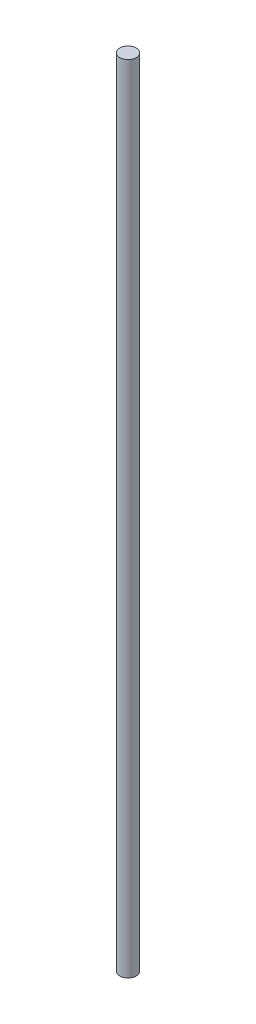
from build123d import *

# Parameters (mm, degrees)
SKETCH1_R           = 4.75
BOSS_EXTRUDE1_DEPTH = 455


with BuildPart() as part:
    # Sketch1 → Boss-Extrude1 (new body)
    with BuildSketch(Plane(origin=(0, 0, 0), x_dir=(1, 0, 0), z_dir=(0, 1, 0))):
        Circle(SKETCH1_R)
    extrude(amount=BOSS_EXTRUDE1_DEPTH)


solid = part.part
